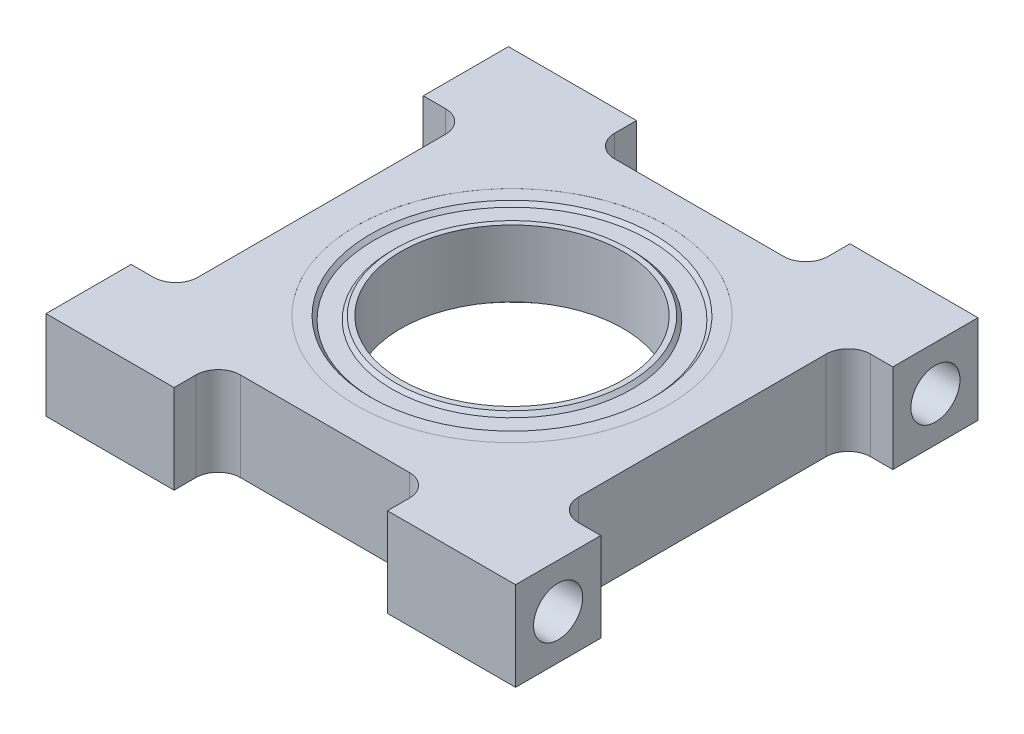
from build123d import *

# Parameters (mm, degrees)
SKETCH1_R                      = 10.16
BOSS_EXTRUDE1_DEPTH            = 6.35
SKETCH2_R                      = 11.1125
CUT_EXTRUDE1_DEPTH             = 4.7625
SKETCH3_R                      = 11.1125
SKETCH3_R_2                    = 9.8425
BOSS_EXTRUDE2_DEPTH            = 4.75996
CHAMFER1_SIZE                  = 0.254
SKETCH4_R                      = 8.5725
SKETCH4_R_2                    = 7.9375
BOSS_EXTRUDE3_DEPTH            = 4.75996
CHAMFER2_SIZE                  = 0.254
SKETCH5_R                      = 9.8425
SKETCH5_R_2                    = 8.5725
BOSS_EXTRUDE4_DEPTH            = 4.2545
F_6_32_TAPPED_HOLE1_AT_2_COUNT = 2
F_6_32_TAPPED_HOLE1_AT_2_PITCH = 26.940768363


with BuildPart() as part:
    # Sketch1 → Boss-Extrude1 (new body)
    with BuildSketch(Plane(origin=(0, 0, 0), x_dir=(1, 0, 0), z_dir=(0, 1, 0))):
        with BuildLine():
            Line((-16.764, -16.51), (-7.62, -16.51))
            Line((-7.62, -16.51), (-7.62, -14.9479))
            ThreePointArc((-7.62, -14.9479), (-7.155032015, -13.825367985), (-6.0325, -13.3604))
            Line((-6.0325, -13.3604), (6.0325, -13.3604))
            ThreePointArc((6.0325, -13.3604), (7.155032015, -13.825367985), (7.62, -14.9479))
            Line((7.62, -14.9479), (7.62, -16.51))
            Line((7.62, -16.51), (16.764, -16.51))
            Line((16.764, -16.51), (16.764, -10.4267))
            Line((16.764, -10.4267), (15.1765, -10.4267))
            ThreePointArc((15.1765, -10.4267), (14.053967985, -9.961732015), (13.589, -8.8392))
            Line((13.589, -8.8392), (13.589, 8.8392))
            ThreePointArc((13.589, 8.8392), (14.053967985, 9.961732015), (15.1765, 10.4267))
            Line((15.1765, 10.4267), (16.764, 10.4267))
            Line((16.764, 10.4267), (16.764, 16.51))
            Line((16.764, 16.51), (7.62, 16.51))
            Line((7.62, 16.51), (7.62, 14.9479))
            ThreePointArc((7.62, 14.9479), (7.155032015, 13.825367985), (6.0325, 13.3604))
            Line((6.0325, 13.3604), (-6.0325, 13.3604))
            ThreePointArc((-6.0325, 13.3604), (-7.155032015, 13.825367985), (-7.62, 14.9479))
            Line((-7.62, 14.9479), (-7.62, 16.51))
            Line((-7.62, 16.51), (-16.764, 16.51))
            Line((-16.764, 16.51), (-16.764, 10.4267))
            Line((-16.764, 10.4267), (-15.1765, 10.4267))
            ThreePointArc((-15.1765, 10.4267), (-14.053967985, 9.961732015), (-13.589, 8.8392))
            Line((-13.589, 8.8392), (-13.589, -8.8392))
            ThreePointArc((-13.589, -8.8392), (-14.053967985, -9.961732015), (-15.1765, -10.4267))
            Line((-15.1765, -10.4267), (-16.764, -10.4267))
            Line((-16.764, -10.4267), (-16.764, -16.51))
        make_face()
        Circle(SKETCH1_R, mode=Mode.SUBTRACT)
    extrude(amount=BOSS_EXTRUDE1_DEPTH)

    # Sketch2 → Cut-Extrude1 (cut)
    with BuildSketch(Plane(origin=(0, 6.35, 0), x_dir=(1, 0, 0), z_dir=(0, 1, 0))):
        Circle(SKETCH2_R)
    extrude(amount=-CUT_EXTRUDE1_DEPTH, mode=Mode.SUBTRACT)

    # Sketch3 → Boss-Extrude2 (add)
    with BuildSketch(Plane(origin=(0, 1.5875, 0), x_dir=(-1, 0, 0), z_dir=(0, 1, 0))):
        Circle(SKETCH3_R)
        Circle(SKETCH3_R_2, mode=Mode.SUBTRACT)
    extrude(amount=BOSS_EXTRUDE2_DEPTH)

    # Chamfer1
    chamfer1_edges = [part.edges().sort_by_distance(p)[0] for p in [
        (9.8425, 1.5875, 0),
        (9.8425, 6.34746, 0),
    ]]
    chamfer(chamfer1_edges, length=CHAMFER1_SIZE)



with BuildPart() as body_2:
    # Sketch4 → Boss-Extrude3 (new body)
    with BuildSketch(Plane(origin=(0, 1.5875, 0), x_dir=(-1, 0, 0), z_dir=(0, 1, 0))):
        Circle(SKETCH4_R)
        Circle(SKETCH4_R_2, mode=Mode.SUBTRACT)
    extrude(amount=BOSS_EXTRUDE3_DEPTH)

    # Chamfer2
    chamfer2_edges = [body_2.edges().sort_by_distance(p)[0] for p in [
        (8.5725, 1.5875, 0),
        (8.5725, 6.34746, 0),
    ]]
    chamfer(chamfer2_edges, length=CHAMFER2_SIZE)


with BuildPart() as part_1:
    add(part.part)

    add(body_2.part)  # Boss-Extrude4 merges body 2
    # Sketch5 → Boss-Extrude4 (add)
    with BuildSketch(Plane(origin=(0, 6.09346, 0), x_dir=(-1, 0, 0), z_dir=(0, 1, 0))):
        Circle(SKETCH5_R)
        Circle(SKETCH5_R_2, mode=Mode.SUBTRACT)
    extrude(amount=-BOSS_EXTRUDE4_DEPTH)

    # Sketch8 → #6-32 Tapped Hole1 (revolve, cut)
    with BuildSketch(Plane(origin=(-16.764, 3.175, -13.470384182), x_dir=(0, 0, 1), z_dir=(0, 1, 0))):
        Polygon((0, 0), (0, 8.76289403), (1.35255, 7.9502), (1.35255, 7.0104), (1.7526, 7.0104), (1.7526, 0), align=None)
    f_6_32_tapped_hole1 = revolve(axis=Axis((-23.114, 3.175, -13.470384182), (1, 0, 0)), mode=Mode.SUBTRACT)

    # #6-32 Tapped Hole1 at 2: #6-32 Tapped Hole1 ×2
    with Locations(*[(0, 0, i * F_6_32_TAPPED_HOLE1_AT_2_PITCH) for i in range(1, F_6_32_TAPPED_HOLE1_AT_2_COUNT)]):
        add(f_6_32_tapped_hole1, mode=Mode.SUBTRACT)

    # Mirror1: #6-32 Tapped Hole1 across plane
    add(f_6_32_tapped_hole1.mirror(Plane(origin=(0, 0, 0), x_dir=(0, 0, 1), z_dir=(1, 0, 0))), mode=Mode.SUBTRACT)

    # Mirror1 copy 1 sketch → Mirror1 copy 1 (revolve, cut)
    with BuildSketch(Plane(origin=(16.764, 3.175, 13.470384182), x_dir=(0, 0, 1), z_dir=(0, 1, 0))):
        Polygon((0, 0), (0, -8.76289403), (1.35255, -7.9502), (1.35255, -7.0104), (1.7526, -7.0104), (1.7526, 0), align=None)
    revolve(axis=Axis((23.114, 3.175, 13.470384182), (1, 0, 0)), mode=Mode.SUBTRACT)


solid = part_1.part
